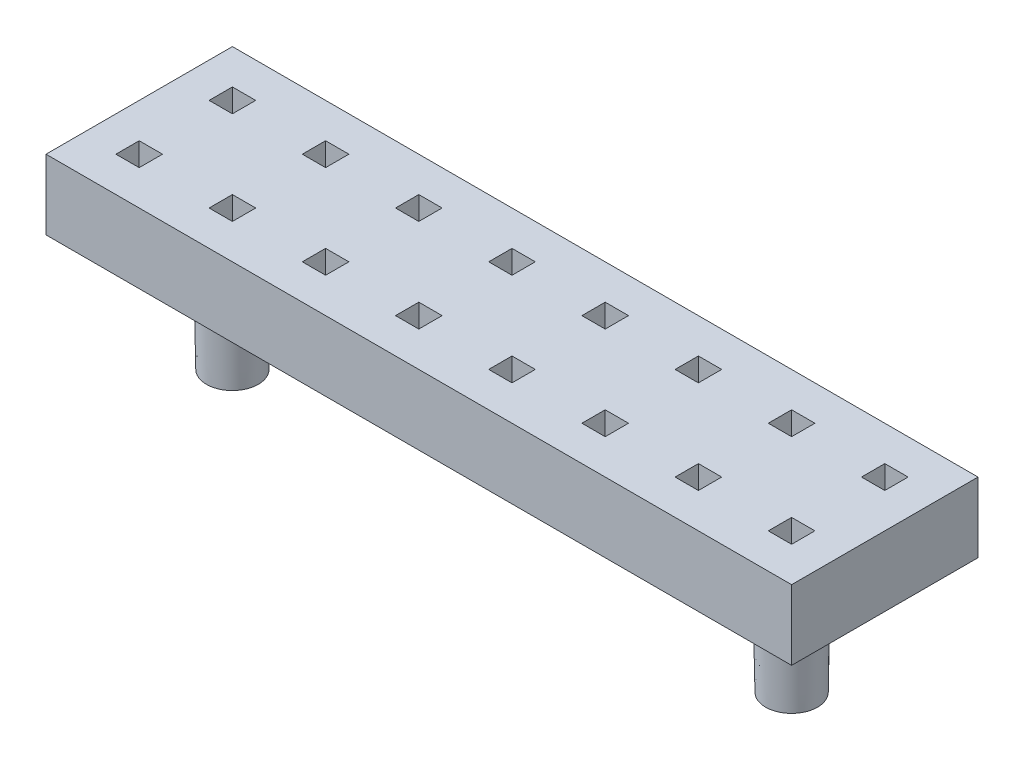
from build123d import *

# Parameters (mm, degrees)
SKETCH1_W                     = 16
SKETCH1_H                     = 4
BOSS_EXTRUDE1_DEPTH           = 1.5
SKETCH2_W                     = 0.5
SKETCH2_H                     = 0.5
CUT_EXTRUDE1_DEPTH            = 2
SKETCH3_R                     = 0.6
BOSS_EXTRUDE2_DEPTH           = 2.5
BOSS_EXTRUDE2_DRAFT           = -1
BOSS_EXTRUDE2_PROFILE_2_DEPTH = 2.5
BOSS_EXTRUDE2_PROFILE_2_DRAFT = -1


with BuildPart() as part:
    # Sketch1 → Boss-Extrude1 (new body)
    with BuildSketch(Plane(origin=(0, 0, 0), x_dir=(1, 0, 0), z_dir=(0, 1, 0))):
        with Locations((8, 2)):
            Rectangle(SKETCH1_W, SKETCH1_H)
    extrude(amount=BOSS_EXTRUDE1_DEPTH)

    # Sketch2 → Cut-Extrude1 (cut)
    with BuildSketch(Plane(origin=(0, 1.5, 0), x_dir=(1, 0, 0), z_dir=(0, 1, 0))):
        with Locations((3, 3)):
            Rectangle(SKETCH2_W, SKETCH2_H)
        with Locations((1, 3)):
            Rectangle(SKETCH2_W, SKETCH2_H)
        with Locations((5, 3)):
            Rectangle(SKETCH2_W, SKETCH2_H)
        with Locations((7, 3)):
            Rectangle(SKETCH2_W, SKETCH2_H)
        with Locations((9, 3)):
            Rectangle(SKETCH2_W, SKETCH2_H)
        with Locations((11, 3)):
            Rectangle(SKETCH2_W, SKETCH2_H)
        with Locations((13, 3)):
            Rectangle(SKETCH2_W, SKETCH2_H)
        with Locations((15, 3)):
            Rectangle(SKETCH2_W, SKETCH2_H)
        with Locations((17, 3)):
            Rectangle(SKETCH2_W, SKETCH2_H)
        with Locations((19, 3)):
            Rectangle(SKETCH2_W, SKETCH2_H)
        with Locations((21, 3)):
            Rectangle(SKETCH2_W, SKETCH2_H)
        with Locations((23, 3)):
            Rectangle(SKETCH2_W, SKETCH2_H)
        with Locations((25, 3)):
            Rectangle(SKETCH2_W, SKETCH2_H)
        with Locations((27, 3)):
            Rectangle(SKETCH2_W, SKETCH2_H)
        with Locations((29, 3)):
            Rectangle(SKETCH2_W, SKETCH2_H)
        with Locations((31, 3)):
            Rectangle(SKETCH2_W, SKETCH2_H)
        with Locations((33, 3)):
            Rectangle(SKETCH2_W, SKETCH2_H)
        with Locations((35, 3)):
            Rectangle(SKETCH2_W, SKETCH2_H)
        with Locations((1, 1)):
            Rectangle(SKETCH2_W, SKETCH2_H)
        with Locations((3, 1)):
            Rectangle(SKETCH2_W, SKETCH2_H)
        with Locations((5, 1)):
            Rectangle(SKETCH2_W, SKETCH2_H)
        with Locations((7, 1)):
            Rectangle(SKETCH2_W, SKETCH2_H)
        with Locations((9, 1)):
            Rectangle(SKETCH2_W, SKETCH2_H)
        with Locations((11, 1)):
            Rectangle(SKETCH2_W, SKETCH2_H)
        with Locations((13, 1)):
            Rectangle(SKETCH2_W, SKETCH2_H)
        with Locations((15, 1)):
            Rectangle(SKETCH2_W, SKETCH2_H)
        with Locations((17, 1)):
            Rectangle(SKETCH2_W, SKETCH2_H)
        with Locations((19, 1)):
            Rectangle(SKETCH2_W, SKETCH2_H)
        with Locations((21, 1)):
            Rectangle(SKETCH2_W, SKETCH2_H)
        with Locations((23, 1)):
            Rectangle(SKETCH2_W, SKETCH2_H)
        with Locations((25, 1)):
            Rectangle(SKETCH2_W, SKETCH2_H)
        with Locations((27, 1)):
            Rectangle(SKETCH2_W, SKETCH2_H)
        with Locations((29, 1)):
            Rectangle(SKETCH2_W, SKETCH2_H)
        with Locations((31, 1)):
            Rectangle(SKETCH2_W, SKETCH2_H)
        with Locations((33, 1)):
            Rectangle(SKETCH2_W, SKETCH2_H)
        with Locations((35, 1)):
            Rectangle(SKETCH2_W, SKETCH2_H)
    extrude(amount=-CUT_EXTRUDE1_DEPTH, mode=Mode.SUBTRACT)


with BuildPart() as boss_extrude2_tool:
    # Sketch3 → Boss-Extrude2 (with draft: the straight prism first)
    with BuildSketch(Plane(origin=(0, 0, 0), x_dir=(1, 0, 0), z_dir=(0, 1, 0))):
        with Locations((2, 2)):
            Circle(SKETCH3_R)
    extrude(amount=-BOSS_EXTRUDE2_DEPTH)
    # Boss-Extrude2: the draft: its side faces are tilted about the plane it starts from
    boss_extrude2_sides = [boss_extrude2_tool.faces().sort_by_distance(p)[0] for p in [
        (1.4, -1.25, -2),
    ]]
    draft(boss_extrude2_sides, Plane(origin=(0, 0, 0), x_dir=(1, 0, 0), z_dir=(0, 1, 0)), BOSS_EXTRUDE2_DRAFT)


with BuildPart() as part_1:
    add(part.part)

    # Boss-Extrude2: add boss_extrude2_tool
    add(boss_extrude2_tool.part)


with BuildPart() as boss_extrude2_profile_2_tool:
    # Sketch3 → Boss-Extrude2 profile 2 (with draft: the straight prism first)
    with BuildSketch(Plane(origin=(0, 0, 0), x_dir=(1, 0, 0), z_dir=(0, 1, 0))):
        with Locations((14, 2)):
            Circle(SKETCH3_R)
    extrude(amount=-BOSS_EXTRUDE2_PROFILE_2_DEPTH)
    # Boss-Extrude2 profile 2: the draft: its side faces are tilted about the plane it starts from
    boss_extrude2_profile_2_sides = [boss_extrude2_profile_2_tool.faces().sort_by_distance(p)[0] for p in [
        (13.4, -1.25, -2),
    ]]
    draft(boss_extrude2_profile_2_sides, Plane(origin=(0, 0, 0), x_dir=(1, 0, 0), z_dir=(0, 1, 0)), BOSS_EXTRUDE2_PROFILE_2_DRAFT)


with BuildPart() as part_2:
    add(part_1.part)

    # Boss-Extrude2 profile 2: add boss_extrude2_profile_2_tool
    add(boss_extrude2_profile_2_tool.part)


solid = part_2.part
